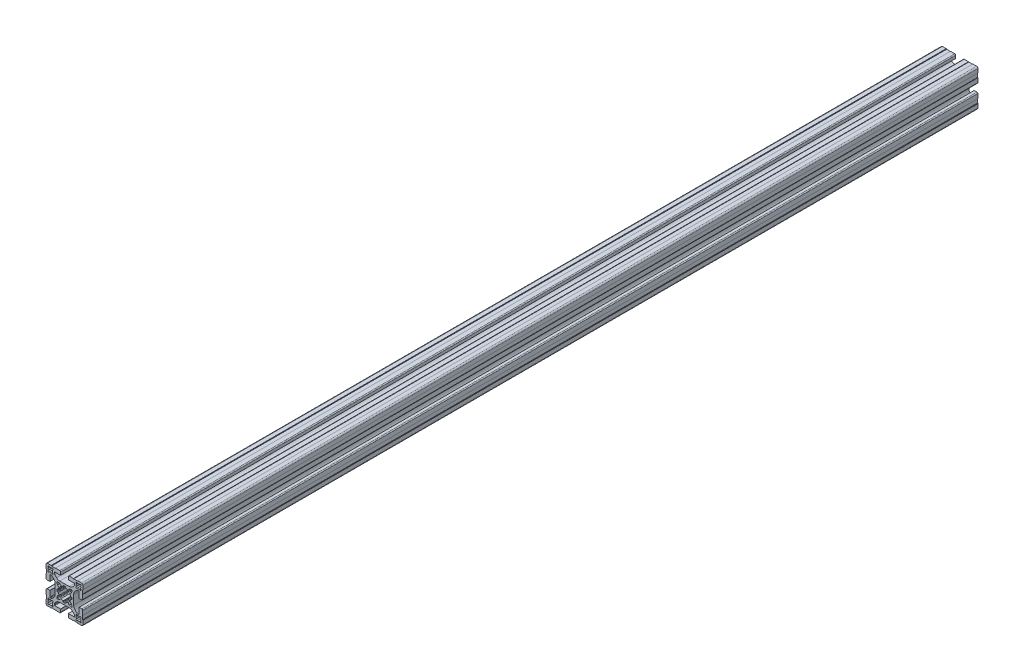
from build123d import *

# Parameters (mm, degrees)
RESSALTO_EXTRUS_O1_DEPTH = 485


with BuildPart() as part:
    # Esboço1 → Ressalto-extrusão1 (new body, symmetric)
    with BuildSketch(Plane.XY):
        with BuildLine():
            Line((4.14998475, -18.79998475), (4.14998475, -15.899980918))
            ThreePointArc((4.14998475, -15.899980918), (4.179274222, -15.829270089), (4.249985176, -15.799980918))
            Line((4.249985176, -15.799980918), (10.499997871, -15.800007531))
            ThreePointArc((10.499997871, -15.800007531), (10.853552638, -15.653561674), (11, -15.300007531))
            Line((11, -15.300007531), (11, -14.449747468))
            ThreePointArc((11, -14.449747468), (10.885819299, -13.87572232), (10.560660172, -13.389087297))
            Line((10.560660172, -13.389087297), (8.636038969, -11.464466094))
            ThreePointArc((8.636038969, -11.464466094), (7.013922225, -10.380602337), (5.100505063, -10))
            Line((5.100505063, -10), (0, -10))
            Line((0, -10), (-5.100505063, -10))
            ThreePointArc((-5.100505063, -10), (-7.013922225, -10.380602337), (-8.636038969, -11.464466094))
            Line((-8.636038969, -11.464466094), (-10.560660172, -13.389087297))
            ThreePointArc((-10.560660172, -13.389087297), (-10.885819299, -13.87572232), (-11, -14.449747468))
            Line((-11, -14.449747468), (-11, -15.300007531))
            ThreePointArc((-11, -15.300007531), (-10.853552638, -15.653561674), (-10.499997871, -15.800007531))
            Line((-10.499997871, -15.800007531), (-4.249985176, -15.799980918))
            ThreePointArc((-4.249985176, -15.799980918), (-4.179274222, -15.829270089), (-4.14998475, -15.899980918))
            Line((-4.14998475, -15.899980918), (-4.14998475, -18.79998475))
            ThreePointArc((-4.14998475, -18.79998475), (-4.442876463, -19.507090026), (-5.149980492, -19.79998475))
            Line((-5.149980492, -19.79998475), (-9.79996495, -19.80000455))
            Line((-9.79996495, -19.80000455), (-9.99998475, -19.59998475))
            Line((-9.99998475, -19.59998475), (-13.99998475, -19.59998475))
            Line((-13.99998475, -19.59998475), (-14.40000475, -20.00000475))
            Line((-14.40000475, -20.00000475), (-18.50000475, -20.00000475))
            ThreePointArc((-18.50000475, -20.00000475), (-19.560664922, -19.560664922), (-20.00000475, -18.50000475))
            Line((-20.00000475, -18.50000475), (-20.00000475, -14.40000475))
            Line((-20.00000475, -14.40000475), (-19.59998475, -13.99998475))
            Line((-19.59998475, -13.99998475), (-19.59998475, -9.99998475))
            Line((-19.59998475, -9.99998475), (-19.800004551, -9.799964949))
            Line((-19.800004551, -9.799964949), (-19.799984751, -5.149980488))
            ThreePointArc((-19.799984751, -5.149980488), (-19.507090026, -4.442876459), (-18.79998475, -4.149984746))
            Line((-18.79998475, -4.149984746), (-15.899980918, -4.149984746))
            ThreePointArc((-15.899980918, -4.149984746), (-15.829270089, -4.179274218), (-15.799980918, -4.249985172))
            Line((-15.799980918, -4.249985172), (-15.800007532, -10.499997871))
            ThreePointArc((-15.800007532, -10.499997871), (-15.653561675, -10.853552638), (-15.300007532, -11))
            Line((-15.300007532, -11), (-14.449747468, -11))
            ThreePointArc((-14.449747468, -11), (-13.87572232, -10.885819298), (-13.389087297, -10.560660171))
            Line((-13.389087297, -10.560660171), (-11.464466094, -8.636038969))
            ThreePointArc((-11.464466094, -8.636038969), (-10.380602337, -7.013922225), (-10, -5.100505063))
            Line((-10, -5.100505063), (-10, 0))
            Line((-10, 0), (-10, 5.100505064))
            ThreePointArc((-10, 5.100505064), (-10.380602337, 7.013922225), (-11.464466094, 8.63603897))
            Line((-11.464466094, 8.63603897), (-13.389087297, 10.560660172))
            ThreePointArc((-13.389087297, 10.560660172), (-13.87572232, 10.885819299), (-14.449747468, 11))
            Line((-14.449747468, 11), (-15.300007532, 11))
            ThreePointArc((-15.300007532, 11), (-15.653561675, 10.853552638), (-15.800007532, 10.499997871))
            Line((-15.800007532, 10.499997871), (-15.799980918, 4.249985172))
            ThreePointArc((-15.799980918, 4.249985172), (-15.829270089, 4.179274219), (-15.899980918, 4.149984747))
            Line((-15.899980918, 4.149984747), (-18.79998475, 4.149984747))
            ThreePointArc((-18.79998475, 4.149984747), (-19.507090026, 4.44287646), (-19.799984751, 5.149980488))
            Line((-19.799984751, 5.149980488), (-19.800004551, 9.79996495))
            Line((-19.800004551, 9.79996495), (-19.59998475, 9.999984751))
            Line((-19.59998475, 9.999984751), (-19.59998475, 13.999984751))
            Line((-19.59998475, 13.999984751), (-20.00000475, 14.400004751))
            Line((-20.00000475, 14.400004751), (-20.00000475, 18.500004751))
            ThreePointArc((-20.00000475, 18.500004751), (-19.560664922, 19.560664922), (-18.50000475, 20.000004751))
            Line((-18.50000475, 20.000004751), (-14.40000475, 20.000004751))
            Line((-14.40000475, 20.000004751), (-13.99998475, 19.599984751))
            Line((-13.99998475, 19.599984751), (-9.99998475, 19.599984751))
            Line((-9.99998475, 19.599984751), (-9.79996495, 19.800004551))
            Line((-9.79996495, 19.800004551), (-5.149980492, 19.799984751))
            ThreePointArc((-5.149980492, 19.799984751), (-4.442876463, 19.507090026), (-4.14998475, 18.799984751))
            Line((-4.14998475, 18.799984751), (-4.14998475, 15.899980918))
            ThreePointArc((-4.14998475, 15.899980918), (-4.179274222, 15.82927009), (-4.249985176, 15.799980918))
            Line((-4.249985176, 15.799980918), (-10.499997871, 15.800007531))
            ThreePointArc((-10.499997871, 15.800007531), (-10.853552638, 15.653561675), (-11, 15.300007531))
            Line((-11, 15.300007531), (-11, 14.449747469))
            ThreePointArc((-11, 14.449747469), (-10.885819299, 13.87572232), (-10.560660172, 13.389087297))
            Line((-10.560660172, 13.389087297), (-8.636038969, 11.464466095))
            ThreePointArc((-8.636038969, 11.464466095), (-7.013922225, 10.380602338), (-5.100505063, 10.000000001))
            Line((-5.100505063, 10.000000001), (0, 10.000000001))
            Line((0, 10.000000001), (5.100505063, 10.000000001))
            ThreePointArc((5.100505063, 10.000000001), (7.013922225, 10.380602338), (8.636038969, 11.464466095))
            Line((8.636038969, 11.464466095), (10.560660172, 13.389087297))
            ThreePointArc((10.560660172, 13.389087297), (10.885819299, 13.87572232), (11, 14.449747469))
            Line((11, 14.449747469), (11, 15.300007531))
            ThreePointArc((11, 15.300007531), (10.853552638, 15.653561675), (10.499997871, 15.800007531))
            Line((10.499997871, 15.800007531), (4.249985176, 15.799980918))
            ThreePointArc((4.249985176, 15.799980918), (4.179274222, 15.82927009), (4.14998475, 15.899980918))
            Line((4.14998475, 15.899980918), (4.14998475, 18.799984751))
            ThreePointArc((4.14998475, 18.799984751), (4.442876463, 19.507090026), (5.149980492, 19.799984751))
            Line((5.149980492, 19.799984751), (9.79996495, 19.800004551))
            Line((9.79996495, 19.800004551), (9.99998475, 19.599984751))
            Line((9.99998475, 19.599984751), (13.99998475, 19.599984751))
            Line((13.99998475, 19.599984751), (14.40000475, 20.000004751))
            Line((14.40000475, 20.000004751), (18.50000475, 20.000004751))
            ThreePointArc((18.50000475, 20.000004751), (19.560664922, 19.560664922), (20.00000475, 18.500004751))
            Line((20.00000475, 18.500004751), (20.00000475, 14.400004751))
            Line((20.00000475, 14.400004751), (19.59998475, 13.999984751))
            Line((19.59998475, 13.999984751), (19.59998475, 9.999984751))
            Line((19.59998475, 9.999984751), (19.800004551, 9.79996495))
            Line((19.800004551, 9.79996495), (19.799984751, 5.149980488))
            ThreePointArc((19.799984751, 5.149980488), (19.507090026, 4.44287646), (18.79998475, 4.149984747))
            Line((18.79998475, 4.149984747), (15.899980918, 4.149984747))
            ThreePointArc((15.899980918, 4.149984747), (15.829270089, 4.179274219), (15.799980918, 4.249985172))
            Line((15.799980918, 4.249985172), (15.800007532, 10.499997871))
            ThreePointArc((15.800007532, 10.499997871), (15.653561675, 10.853552638), (15.300007532, 11))
            Line((15.300007532, 11), (14.449747468, 11))
            ThreePointArc((14.449747468, 11), (13.87572232, 10.885819299), (13.389087297, 10.560660172))
            Line((13.389087297, 10.560660172), (11.464466094, 8.63603897))
            ThreePointArc((11.464466094, 8.63603897), (10.380602337, 7.013922225), (10, 5.100505064))
            Line((10, 5.100505064), (10, 0))
            Line((10, 0), (10, -5.100505063))
            ThreePointArc((10, -5.100505063), (10.380602337, -7.013922225), (11.464466094, -8.636038969))
            Line((11.464466094, -8.636038969), (13.389087297, -10.560660171))
            ThreePointArc((13.389087297, -10.560660171), (13.87572232, -10.885819298), (14.449747468, -11))
            Line((14.449747468, -11), (15.300007532, -11))
            ThreePointArc((15.300007532, -11), (15.653561675, -10.853552638), (15.800007532, -10.499997871))
            Line((15.800007532, -10.499997871), (15.799980918, -4.249985172))
            ThreePointArc((15.799980918, -4.249985172), (15.829270089, -4.179274218), (15.899980918, -4.149984746))
            Line((15.899980918, -4.149984746), (18.79998475, -4.149984746))
            ThreePointArc((18.79998475, -4.149984746), (19.507090026, -4.442876459), (19.799984751, -5.149980488))
            Line((19.799984751, -5.149980488), (19.800004551, -9.799964949))
            Line((19.800004551, -9.799964949), (19.59998475, -9.99998475))
            Line((19.59998475, -9.99998475), (19.59998475, -13.99998475))
            Line((19.59998475, -13.99998475), (20.00000475, -14.40000475))
            Line((20.00000475, -14.40000475), (20.00000475, -18.50000475))
            ThreePointArc((20.00000475, -18.50000475), (19.560664922, -19.560664922), (18.50000475, -20.00000475))
            Line((18.50000475, -20.00000475), (14.40000475, -20.00000475))
            Line((14.40000475, -20.00000475), (13.99998475, -19.59998475))
            Line((13.99998475, -19.59998475), (9.99998475, -19.59998475))
            Line((9.99998475, -19.59998475), (9.79996495, -19.80000455))
            Line((9.79996495, -19.80000455), (5.149980492, -19.79998475))
            ThreePointArc((5.149980492, -19.79998475), (4.442876463, -19.507090026), (4.14998475, -18.79998475))
        make_face()
        with BuildLine():
            Line((-17.857240871, 16.796580699), (-17.416672281, 16.356012109))
            ThreePointArc((-17.416672281, 16.356012109), (-17.7, 15.2), (-17.416672281, 14.04398789))
            Line((-17.416672281, 14.04398789), (-17.857240871, 13.603419301))
            ThreePointArc((-17.857240871, 13.603419301), (-17.857240871, 12.542759129), (-16.796580699, 12.542759129))
            Line((-16.796580699, 12.542759129), (-16.35601211, 12.983327719))
            ThreePointArc((-16.35601211, 12.983327719), (-15.2, 12.7), (-14.04398789, 12.983327719))
            Line((-14.04398789, 12.983327719), (-13.603419301, 12.542759129))
            ThreePointArc((-13.603419301, 12.542759129), (-12.542759129, 12.542759129), (-12.542759129, 13.603419301))
            Line((-12.542759129, 13.603419301), (-12.983327719, 14.04398789))
            ThreePointArc((-12.983327719, 14.04398789), (-12.7, 15.2), (-12.983327719, 16.356012109))
            Line((-12.983327719, 16.356012109), (-12.542759081, 16.796580747))
            ThreePointArc((-12.542759081, 16.796580747), (-12.542759081, 17.857240919), (-13.603419253, 17.857240919))
            Line((-13.603419253, 17.857240919), (-14.04398789, 17.416672281))
            ThreePointArc((-14.04398789, 17.416672281), (-15.2, 17.7), (-16.35601211, 17.416672281))
            Line((-16.35601211, 17.416672281), (-16.796580699, 17.857240871))
            ThreePointArc((-16.796580699, 17.857240871), (-17.857240871, 17.857240871), (-17.857240871, 16.796580699))
        make_face(mode=Mode.SUBTRACT)
        with BuildLine():
            Line((17.416672281, 14.04398789), (17.857240871, 13.603419301))
            ThreePointArc((17.857240871, 13.603419301), (17.857240871, 12.542759129), (16.796580699, 12.542759129))
            Line((16.796580699, 12.542759129), (16.35601211, 12.983327719))
            ThreePointArc((16.35601211, 12.983327719), (15.2, 12.7), (14.043987891, 12.983327719))
            Line((14.043987891, 12.983327719), (13.603419301, 12.542759129))
            ThreePointArc((13.603419301, 12.542759129), (12.542759129, 12.542759129), (12.542759129, 13.603419301))
            Line((12.542759129, 13.603419301), (12.983327719, 14.04398789))
            ThreePointArc((12.983327719, 14.04398789), (12.7, 15.2), (12.983327719, 16.356012109))
            Line((12.983327719, 16.356012109), (12.542759081, 16.796580747))
            ThreePointArc((12.542759081, 16.796580747), (12.542759081, 17.857240919), (13.603419253, 17.857240919))
            Line((13.603419253, 17.857240919), (14.043987891, 17.416672281))
            ThreePointArc((14.043987891, 17.416672281), (15.2, 17.7), (16.35601211, 17.416672281))
            Line((16.35601211, 17.416672281), (16.796580699, 17.857240871))
            ThreePointArc((16.796580699, 17.857240871), (17.857240871, 17.857240871), (17.857240871, 16.796580699))
            Line((17.857240871, 16.796580699), (17.416672281, 16.356012109))
            ThreePointArc((17.416672281, 16.356012109), (17.7, 15.2), (17.416672281, 14.04398789))
        make_face(mode=Mode.SUBTRACT)
        with BuildLine():
            Line((-17.416672281, -14.04398789), (-17.857240871, -13.603419301))
            ThreePointArc((-17.857240871, -13.603419301), (-17.857240871, -12.542759129), (-16.796580699, -12.542759129))
            Line((-16.796580699, -12.542759129), (-16.35601211, -12.983327719))
            ThreePointArc((-16.35601211, -12.983327719), (-15.2, -12.7), (-14.04398789, -12.983327719))
            Line((-14.04398789, -12.983327719), (-13.603419301, -12.542759129))
            ThreePointArc((-13.603419301, -12.542759129), (-12.542759129, -12.542759129), (-12.542759129, -13.603419301))
            Line((-12.542759129, -13.603419301), (-12.983327719, -14.04398789))
            ThreePointArc((-12.983327719, -14.04398789), (-12.7, -15.2), (-12.983327719, -16.35601211))
            Line((-12.983327719, -16.35601211), (-12.542759081, -16.796580747))
            ThreePointArc((-12.542759081, -16.796580747), (-12.542759081, -17.857240919), (-13.603419253, -17.857240919))
            Line((-13.603419253, -17.857240919), (-14.04398789, -17.416672281))
            ThreePointArc((-14.04398789, -17.416672281), (-15.2, -17.7), (-16.35601211, -17.416672281))
            Line((-16.35601211, -17.416672281), (-16.796580699, -17.857240871))
            ThreePointArc((-16.796580699, -17.857240871), (-17.857240871, -17.857240871), (-17.857240871, -16.796580699))
            Line((-17.857240871, -16.796580699), (-17.416672281, -16.35601211))
            ThreePointArc((-17.416672281, -16.35601211), (-17.7, -15.2), (-17.416672281, -14.04398789))
        make_face(mode=Mode.SUBTRACT)
        with BuildLine():
            Line((17.857240871, -16.796580699), (17.416672281, -16.35601211))
            ThreePointArc((17.416672281, -16.35601211), (17.7, -15.2), (17.416672281, -14.04398789))
            Line((17.416672281, -14.04398789), (17.857240871, -13.603419301))
            ThreePointArc((17.857240871, -13.603419301), (17.857240871, -12.542759129), (16.796580699, -12.542759129))
            Line((16.796580699, -12.542759129), (16.35601211, -12.983327719))
            ThreePointArc((16.35601211, -12.983327719), (15.2, -12.7), (14.043987891, -12.983327719))
            Line((14.043987891, -12.983327719), (13.603419301, -12.542759129))
            ThreePointArc((13.603419301, -12.542759129), (12.542759129, -12.542759129), (12.542759129, -13.603419301))
            Line((12.542759129, -13.603419301), (12.983327719, -14.04398789))
            ThreePointArc((12.983327719, -14.04398789), (12.7, -15.2), (12.983327719, -16.35601211))
            Line((12.983327719, -16.35601211), (12.542759081, -16.796580747))
            ThreePointArc((12.542759081, -16.796580747), (12.542759081, -17.857240919), (13.603419253, -17.857240919))
            Line((13.603419253, -17.857240919), (14.043987891, -17.416672281))
            ThreePointArc((14.043987891, -17.416672281), (15.2, -17.7), (16.35601211, -17.416672281))
            Line((16.35601211, -17.416672281), (16.796580699, -17.857240871))
            ThreePointArc((16.796580699, -17.857240871), (17.857240871, -17.857240871), (17.857240871, -16.796580699))
        make_face(mode=Mode.SUBTRACT)
        with BuildLine():
            Line((-5.31389005, -7.63550963), (-7.648765071, -8.261137506))
            ThreePointArc((-7.648765071, -8.261137506), (-8.131727984, -8.131727984), (-8.261137506, -7.64876507))
            Line((-8.261137506, -7.64876507), (-7.63550963, -5.313890049))
            ThreePointArc((-7.63550963, -5.313890049), (-7.568281523, -5.165514456), (-7.456927431, -5.046622902))
            Line((-7.456927431, -5.046622902), (-5.743958929, -3.73221594))
            ThreePointArc((-5.743958929, -3.73221594), (-6.328574798, -2.621381512), (-6.70066751, -1.422517109))
            Line((-6.70066751, -1.422517109), (-7.520425705, -1.314593895))
            ThreePointArc((-7.520425705, -1.314593895), (-7.812495975, -1.168604027), (-7.952173449, -0.873462896))
            ThreePointArc((-7.952173449, -0.873462896), (-8, 0), (-7.952173449, 0.873462896))
            ThreePointArc((-7.952173449, 0.873462896), (-7.812495975, 1.168604027), (-7.520425705, 1.314593895))
            Line((-7.520425705, 1.314593895), (-6.70066751, 1.422517109))
            ThreePointArc((-6.70066751, 1.422517109), (-6.328574798, 2.621381512), (-5.743958929, 3.73221594))
            Line((-5.743958929, 3.73221594), (-7.456927431, 5.046622902))
            ThreePointArc((-7.456927431, 5.046622902), (-7.568281523, 5.165514456), (-7.63550963, 5.313890049))
            Line((-7.63550963, 5.313890049), (-8.261137506, 7.64876507))
            ThreePointArc((-8.261137506, 7.64876507), (-8.131727984, 8.131727984), (-7.648765071, 8.261137506))
            Line((-7.648765071, 8.261137506), (-5.31389005, 7.63550963))
            ThreePointArc((-5.31389005, 7.63550963), (-5.165514456, 7.568281523), (-5.046622902, 7.456927431))
            Line((-5.046622902, 7.456927431), (-3.73221594, 5.743958929))
            ThreePointArc((-3.73221594, 5.743958929), (-2.621381512, 6.328574798), (-1.422517109, 6.70066751))
            Line((-1.422517109, 6.70066751), (-1.314593895, 7.520425705))
            ThreePointArc((-1.314593895, 7.520425705), (-1.168604027, 7.812495975), (-0.873462896, 7.952173449))
            ThreePointArc((-0.873462896, 7.952173449), (0, 8), (0.873462896, 7.952173449))
            ThreePointArc((0.873462896, 7.952173449), (1.168604027, 7.812495975), (1.314593895, 7.520425705))
            Line((1.314593895, 7.520425705), (1.422517109, 6.70066751))
            ThreePointArc((1.422517109, 6.70066751), (2.621381512, 6.328574798), (3.73221594, 5.743958929))
            Line((3.73221594, 5.743958929), (5.046622902, 7.456927431))
            ThreePointArc((5.046622902, 7.456927431), (5.165514456, 7.568281523), (5.31389005, 7.63550963))
            Line((5.31389005, 7.63550963), (7.648765071, 8.261137506))
            ThreePointArc((7.648765071, 8.261137506), (8.131727984, 8.131727984), (8.261137506, 7.64876507))
            Line((8.261137506, 7.64876507), (7.63550963, 5.313890049))
            ThreePointArc((7.63550963, 5.313890049), (7.568281523, 5.165514456), (7.456927431, 5.046622902))
            Line((7.456927431, 5.046622902), (5.743958929, 3.73221594))
            ThreePointArc((5.743958929, 3.73221594), (6.328574798, 2.621381512), (6.70066751, 1.422517109))
            Line((6.70066751, 1.422517109), (7.520425705, 1.314593895))
            ThreePointArc((7.520425705, 1.314593895), (7.812495975, 1.168604027), (7.952173449, 0.873462896))
            ThreePointArc((7.952173449, 0.873462896), (8, 0), (7.952173449, -0.873462896))
            ThreePointArc((7.952173449, -0.873462896), (7.812495975, -1.168604027), (7.520425705, -1.314593895))
            Line((7.520425705, -1.314593895), (6.70066751, -1.422517109))
            ThreePointArc((6.70066751, -1.422517109), (6.328574798, -2.621381512), (5.743958929, -3.73221594))
            Line((5.743958929, -3.73221594), (7.456927431, -5.046622902))
            ThreePointArc((7.456927431, -5.046622902), (7.568281523, -5.165514456), (7.63550963, -5.313890049))
            Line((7.63550963, -5.313890049), (8.261137506, -7.64876507))
            ThreePointArc((8.261137506, -7.64876507), (8.131727984, -8.131727984), (7.648765071, -8.261137506))
            Line((7.648765071, -8.261137506), (5.31389005, -7.63550963))
            ThreePointArc((5.31389005, -7.63550963), (5.165514456, -7.568281523), (5.046622902, -7.456927431))
            Line((5.046622902, -7.456927431), (3.73221594, -5.743958929))
            ThreePointArc((3.73221594, -5.743958929), (2.621381512, -6.328574798), (1.422517109, -6.70066751))
            Line((1.422517109, -6.70066751), (1.314593895, -7.520425705))
            ThreePointArc((1.314593895, -7.520425705), (1.168604027, -7.812495975), (0.873462896, -7.952173449))
            ThreePointArc((0.873462896, -7.952173449), (0, -8), (-0.873462896, -7.952173449))
            ThreePointArc((-0.873462896, -7.952173449), (-1.168604027, -7.812495975), (-1.314593895, -7.520425705))
            Line((-1.314593895, -7.520425705), (-1.422517109, -6.70066751))
            ThreePointArc((-1.422517109, -6.70066751), (-2.621381512, -6.328574798), (-3.73221594, -5.743958929))
            Line((-3.73221594, -5.743958929), (-5.046622902, -7.456927431))
            ThreePointArc((-5.046622902, -7.456927431), (-5.165514456, -7.568281523), (-5.31389005, -7.63550963))
        make_face(mode=Mode.SUBTRACT)
    extrude(amount=RESSALTO_EXTRUS_O1_DEPTH, both=True)


solid = part.part
